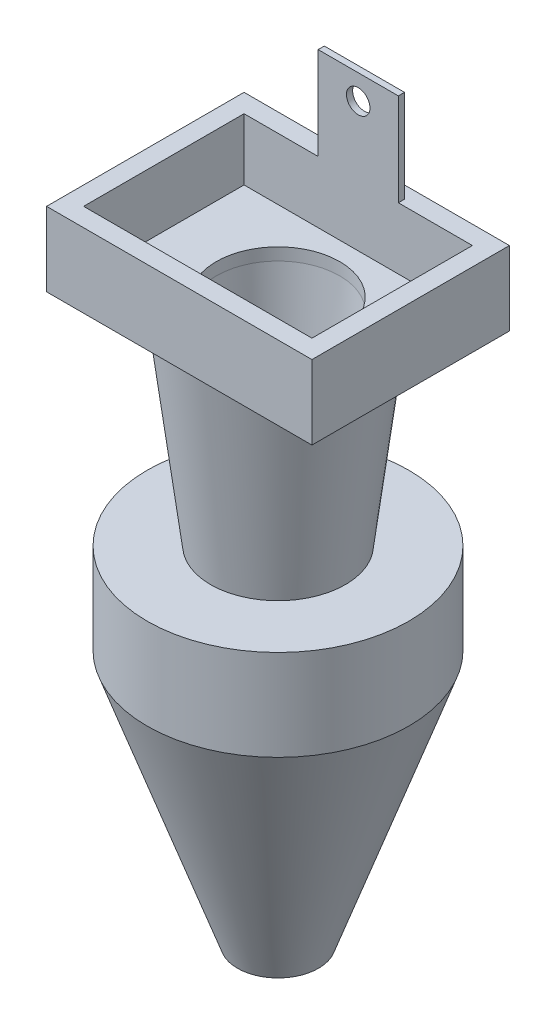
from build123d import *

# Parameters (mm, degrees)
SKETCH1_W           = 43
SKETCH1_H           = 32
SKETCH1_W_2         = 37
SKETCH1_H_2         = 26
BOSS_EXTRUDE1_DEPTH = 10
SKETCH2_W           = 13
SKETCH2_H           = 1
BOSS_EXTRUDE2_DEPTH = 15
CUT_EXTRUDE1_REACH  = 32
SKETCH3_R           = 1.905
SKETCH4_W           = 43
SKETCH4_H           = 32
BOSS_EXTRUDE3_DEPTH = 2
CUT_EXTRUDE2_REACH  = 29
SKETCH5_R           = 10
CUT_EXTRUDE3_START  = 10
SKETCH11_R          = 3.175
CUT_EXTRUDE3_DEPTH  = 15


with BuildPart() as part:
    # Sketch1 → Boss-Extrude1 (new body)
    with BuildSketch(Plane(origin=(0, 0, 0), x_dir=(1, 0, 0), z_dir=(0, 1, 0))):
        with Locations((18.5, 13)):
            Rectangle(SKETCH1_W, SKETCH1_H)
        with Locations((18.5, 13)):
            Rectangle(SKETCH1_W_2, SKETCH1_H_2, mode=Mode.SUBTRACT)
    extrude(amount=BOSS_EXTRUDE1_DEPTH)

    # Sketch2 → Boss-Extrude2 (add)
    with BuildSketch(Plane(origin=(0, 10, 0), x_dir=(1, 0, 0), z_dir=(0, 1, 0))):
        with Locations((18.5, 26.5)):
            Rectangle(SKETCH2_W, SKETCH2_H)
    extrude(amount=BOSS_EXTRUDE2_DEPTH)

    # Sketch3 → Cut-Extrude1 (cut, up to next)
    with BuildSketch(Plane(origin=(0, 0, -27), x_dir=(-1, 0, 0), z_dir=(0, 0, -1)), mode=Mode.PRIVATE) as cut_extrude1_sk1:
        with Locations((-18.5, 21)):
            Circle(SKETCH3_R)
    cut_extrude1_tool1 = extrude(cut_extrude1_sk1.sketch, amount=-CUT_EXTRUDE1_REACH, mode=Mode.PRIVATE) & part.part
    add(cut_extrude1_tool1.solids().sort_by_distance((18.5, 21, -27))[0], mode=Mode.SUBTRACT)

    # Sketch4 → Boss-Extrude3 (add)
    with BuildSketch(Plane.XZ):
        with Locations((18.5, -13)):
            Rectangle(SKETCH4_W, SKETCH4_H)
    extrude(amount=BOSS_EXTRUDE3_DEPTH)

    # Sketch5 → Cut-Extrude2 (cut, up to next)
    with BuildSketch(Plane.XZ.offset(2), mode=Mode.PRIVATE) as cut_extrude2_sk1:
        with Locations((18.5, -13)):
            Circle(SKETCH5_R)
    cut_extrude2_tool1 = extrude(cut_extrude2_sk1.sketch, amount=-CUT_EXTRUDE2_REACH, mode=Mode.PRIVATE) & part.part
    add(cut_extrude2_tool1.solids().sort_by_distance((18.5, -2, -13))[0], mode=Mode.SUBTRACT)

    # Sketch9 → Revolve1 (revolve)
    with BuildSketch(Plane.XY.offset(-13)):
        Polygon((28.5, -2), (21.5, -90.9), (22.5, -90.9), (33.5, -2), align=None)
    revolve(axis=Axis((18.5, -2, -13), (0, -1, 0)))

    # Sketch10 → Revolve2 (revolve)
    with BuildSketch(Plane.XY.offset(-13)):
        Polygon((12.988560941, -90.9), (8.633183769, -49.593045745), (0.378993359, -49.593045745), (0.378993359, -38.393027141), (8.003074224, -38.393027141), (7.567144174, -34.86991973), (-2.696890299, -34.86991973), (-2.696890299, -49.593045745), (11.935583953, -90.9), align=None)
    revolve(axis=Axis((18.5, -2, -13), (0, -1, 0)))

    # Sketch11 → Cut-Extrude3 (cut)
    with BuildSketch(Plane.ZY.offset(3).offset(CUT_EXTRUDE3_START)):
        with Locations((-16.217164304, -43.610889084)):
            Circle(SKETCH11_R)
    extrude(amount=-CUT_EXTRUDE3_DEPTH, mode=Mode.SUBTRACT)


solid = part.part
